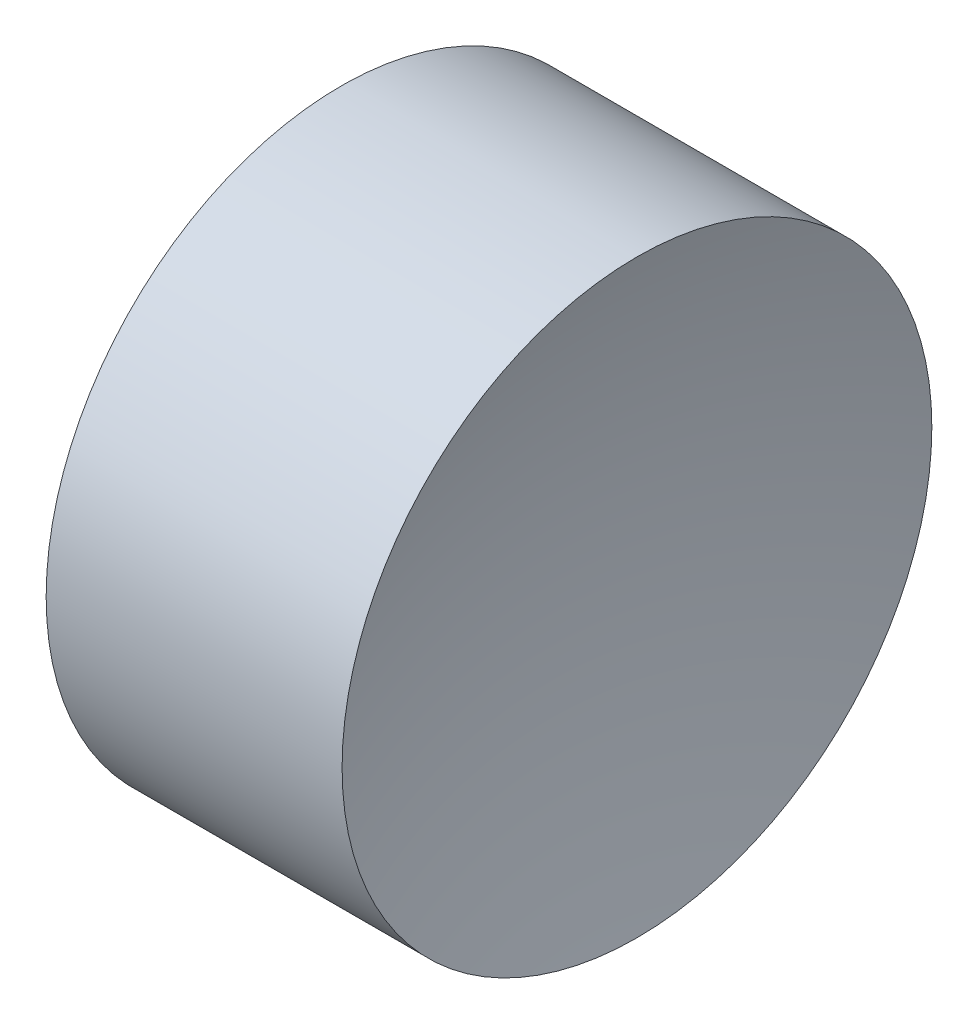
from build123d import *


with BuildPart() as part:
    # 草图1 → 旋转1 (revolve)
    with BuildSketch(Plane.XY):
        with BuildLine():
            Line((11.080595085, 6.515563046), (11.080595085, 8.515563046))
            Line((11.080595085, 8.515563046), (13.08770818, 8.515563046))
            ThreePointArc((13.08770818, 8.515563046), (12.865278711, 7.526537352), (12.790595085, 6.515563046))
            Line((12.790595085, 6.515563046), (11.080595085, 6.515563046))
        make_face()
    revolve(axis=Axis((10.578235961, 6.515563046, 0), (1, 0, 0)))


solid = part.part
